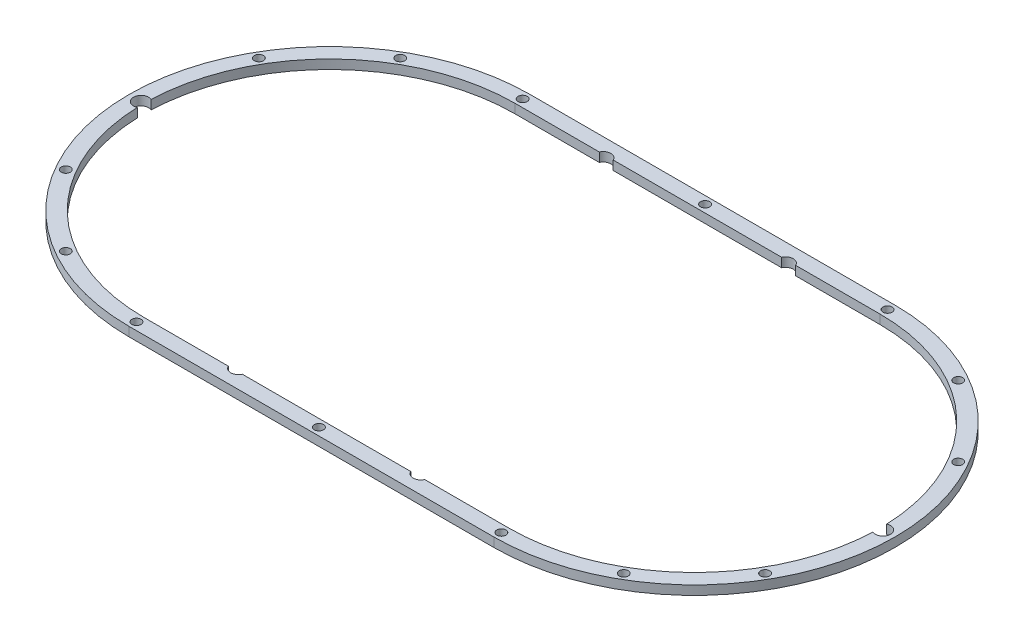
from build123d import *

# Parameters (mm, degrees)
SKETCH_1_R          = 1.5
EXTRUDE_2_DEPTH     = 3
CUT_EXTRUDE_1_DEPTH = 10
SKETCH_4_R          = 7.5
CUT_EXTRUDE_2_DEPTH = 10
SKETCH_5_R          = 1.5
CUT_EXTRUDE_3_DEPTH = 10
CUT_EXTRUDE_4_DEPTH = 10


with BuildPart() as part:
    # 草图1 → 凸台-拉伸2 (new body)
    with BuildSketch(Plane(origin=(0, 0, 0), x_dir=(1, 0, 0), z_dir=(0, 1, 0))):
        with BuildLine():
            Line((-60, 70), (60, 70))
            ThreePointArc((60, 70), (130, 0), (60, -70))
            Line((60, -70), (-60, -70))
            ThreePointArc((-60, -70), (-130, 0), (-60, 70))
        make_face()
        with Locations((-122, 0)):
            Circle(SKETCH_1_R, mode=Mode.SUBTRACT)
        with Locations((122, 0)):
            Circle(SKETCH_1_R, mode=Mode.SUBTRACT)
        with Locations((-30, 60)):
            Circle(SKETCH_1_R, mode=Mode.SUBTRACT)
        with Locations((30, 60)):
            Circle(SKETCH_1_R, mode=Mode.SUBTRACT)
        with Locations((30, -60)):
            Circle(SKETCH_1_R, mode=Mode.SUBTRACT)
        with Locations((-30, -60)):
            Circle(SKETCH_1_R, mode=Mode.SUBTRACT)
    extrude(amount=EXTRUDE_2_DEPTH)

    # 草图3 → 切除-拉伸1 (cut)
    with BuildSketch(Plane(origin=(0, 3, 0), x_dir=(1, 0, 0), z_dir=(0, 1, 0))):
        with BuildLine():
            Line((-60, -70), (60, -70))
            ThreePointArc((60, -70), (130, 0), (60, 70))
            Line((60, 70), (-60, 70))
            ThreePointArc((-60, 70), (-130, 0), (-60, -70))
        make_face()
        with BuildLine():
            Line((-60, -66), (60, -66))
            ThreePointArc((60, -66), (126, 0), (60, 66))
            Line((60, 66), (-60, 66))
            ThreePointArc((-60, 66), (-126, 0), (-60, -66))
        make_face(mode=Mode.SUBTRACT)
    extrude(amount=-CUT_EXTRUDE_1_DEPTH, mode=Mode.SUBTRACT)

    # 草图4 → 切除-拉伸2 (cut)
    with BuildSketch(Plane(origin=(0, 3, 0), x_dir=(1, 0, 0), z_dir=(0, 1, 0))):
        with Locations((-96, 0)):
            Circle(SKETCH_4_R)
        with Locations((96, 0)):
            Circle(SKETCH_4_R)
        with Locations((0, 36)):
            Circle(SKETCH_4_R)
        with Locations((0, -36)):
            Circle(SKETCH_4_R)
        with Locations((-60, -36)):
            Circle(SKETCH_4_R)
        with Locations((60, -36)):
            Circle(SKETCH_4_R)
        with Locations((30, -36)):
            Circle(SKETCH_4_R)
        with Locations((-30, -36)):
            Circle(SKETCH_4_R)
        with Locations((-85.455844123, -25.455844123)):
            Circle(SKETCH_4_R)
        with Locations((60, 36)):
            Circle(SKETCH_4_R)
        with Locations((30, 36)):
            Circle(SKETCH_4_R)
        with Locations((-85.455844123, 25.455844123)):
            Circle(SKETCH_4_R)
        with Locations((-30, 36)):
            Circle(SKETCH_4_R)
        with Locations((-60, 36)):
            Circle(SKETCH_4_R)
        with Locations((85.455844123, -25.455844123)):
            Circle(SKETCH_4_R)
        with Locations((85.455844123, 25.455844123)):
            Circle(SKETCH_4_R)
    extrude(amount=-CUT_EXTRUDE_2_DEPTH, mode=Mode.SUBTRACT)

    # 草图5 → 切除-拉伸3 (cut)
    with BuildSketch(Plane(origin=(0, 3, 0), x_dir=(1, 0, 0), z_dir=(0, 1, 0))):
        with Locations((-60, 63.5)):
            Circle(SKETCH_5_R)
        with Locations((114.99261314, 31.75)):
            Circle(SKETCH_5_R)
        with Locations((0, 63.5)):
            Circle(SKETCH_5_R)
        with Locations((60, 63.5)):
            Circle(SKETCH_5_R)
        with Locations((91.75, 54.99261314)):
            Circle(SKETCH_5_R)
        with Locations((91.75, -54.99261314)):
            Circle(SKETCH_5_R)
        with Locations((114.99261314, -31.75)):
            Circle(SKETCH_5_R)
        with Locations((-91.75, -54.99261314)):
            Circle(SKETCH_5_R)
        with Locations((-114.99261314, -31.75)):
            Circle(SKETCH_5_R)
        with Locations((-91.75, 54.99261314)):
            Circle(SKETCH_5_R)
        with Locations((-114.99261314, 31.75)):
            Circle(SKETCH_5_R)
        with Locations((60, -63.5)):
            Circle(SKETCH_5_R)
        with Locations((0, -63.5)):
            Circle(SKETCH_5_R)
        with Locations((-60, -63.5)):
            Circle(SKETCH_5_R)
    extrude(amount=-CUT_EXTRUDE_3_DEPTH, mode=Mode.SUBTRACT)

    # 草图6 → 切除-拉伸4 (cut)
    with BuildSketch(Plane(origin=(0, 3, 0), x_dir=(1, 0, 0), z_dir=(0, 1, 0))):
        with BuildLine():
            Line((60, 61), (32.291287847, 61))
            ThreePointArc((32.291287847, 61), (30, 62.5), (27.708712153, 61))
            Line((27.708712153, 61), (-27.708712153, 61))
            ThreePointArc((-27.708712153, 61), (-30, 62.5), (-32.291287847, 61))
            Line((-32.291287847, 61), (-60, 61))
            ThreePointArc((-60, 61), (-102.322495481, 43.929561531), (-120.95766129, 2.272340207))
            ThreePointArc((-120.95766129, 2.272340207), (-124.5, 0), (-120.95766129, -2.272340207))
            ThreePointArc((-120.95766129, -2.272340207), (-102.322495481, -43.929561531), (-60, -61))
            Line((-60, -61), (-32.291287847, -61))
            ThreePointArc((-32.291287847, -61), (-30, -62.5), (-27.708712153, -61))
            Line((-27.708712153, -61), (27.708712153, -61))
            ThreePointArc((27.708712153, -61), (30, -62.5), (32.291287847, -61))
            Line((32.291287847, -61), (60, -61))
            ThreePointArc((60, -61), (102.322495481, -43.929561531), (120.95766129, -2.272340207))
            ThreePointArc((120.95766129, -2.272340207), (124.5, 0), (120.95766129, 2.272340207))
            ThreePointArc((120.95766129, 2.272340207), (102.322495481, 43.929561531), (60, 61))
        make_face()
    extrude(amount=-CUT_EXTRUDE_4_DEPTH, mode=Mode.SUBTRACT)


solid = part.part
